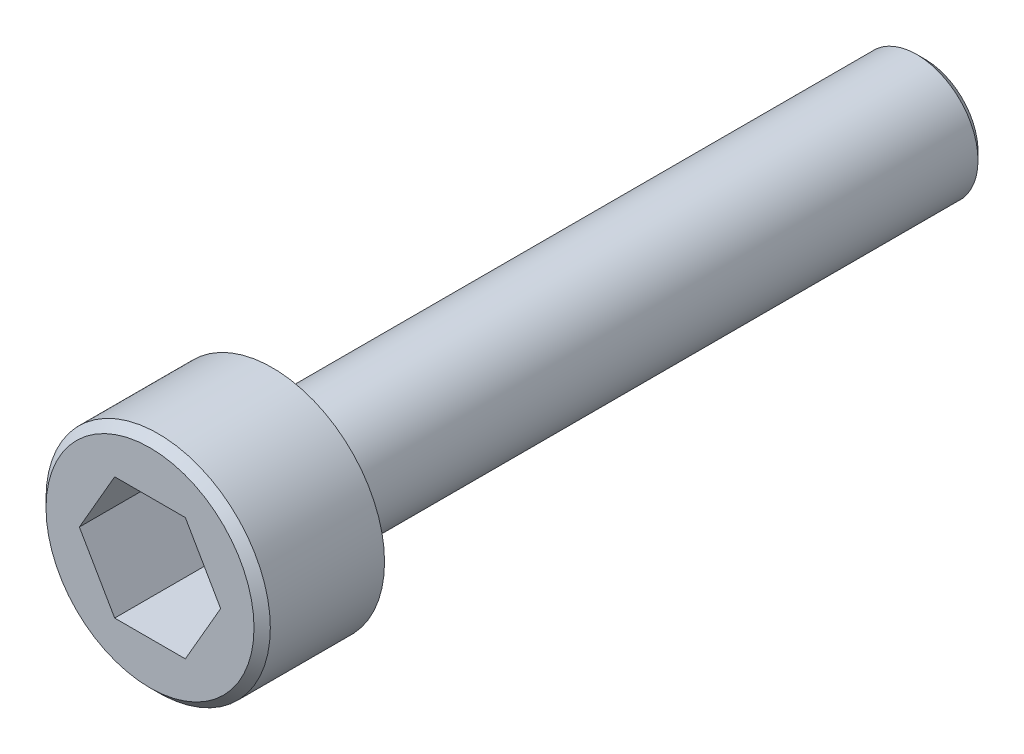
from build123d import *

# Parameters (mm, degrees)
CHAMFER_1_SIZE      = 0.2
CHAMFER_2_SIZE      = 0.2
CUT_EXTRUDE_1_DEPTH = 2.4
EXTRUDE_2_REACH     = 21.394
SKETCH_4_R          = 1.832050808


with BuildPart() as part:
    # Sketch S → Revolve D (revolve)
    with BuildSketch(Plane(origin=(0, 0, 0), x_dir=(-1, 0, 0), z_dir=(0, 1, 0))):
        Polygon((0, 0), (2.75, 0), (2.75, -3), (1.5, -3), (1.5, -19), (0, -19), align=None)
    revolve(axis=Axis((0, 0, 20), (0, 0, -1)))

    # 面取り1
    chamfer_1_edges = [part.edges().sort_by_distance(p)[0] for p in [
        (2.75, 0, 0),
    ]]
    chamfer(chamfer_1_edges, length=CHAMFER_1_SIZE)

    # 面取り2
    chamfer_2_edges = [part.edges().sort_by_distance(p)[0] for p in [
        (1.5, 0, -19),
    ]]
    chamfer(chamfer_2_edges, length=CHAMFER_2_SIZE)

    # ｽｹｯﾁ2 → ｶｯﾄ - 押し出し1 (cut)
    with BuildSketch(Plane(origin=(0, 0, 0), x_dir=(0, 1, 0), z_dir=(0, 0, 1))):
        Polygon((0, 1.732050808), (1.5, 0.866025404), (1.5, -0.866025404), (0, -1.732050808), (-1.5, -0.866025404), (-1.5, 0.866025404), align=None)
    extrude(amount=-CUT_EXTRUDE_1_DEPTH, mode=Mode.SUBTRACT)

    # ｽｹｯﾁ3 → ｶｯﾄ - 回転1 (revolve, cut)
    with BuildSketch(Plane(origin=(0, 0, 0), x_dir=(1, 0, 0), z_dir=(0, 1, 0))):
        Polygon((-1.832050808, 0), (0, 0), (0, 3.4), (-1.832050808, 2.342264973), align=None)
    revolve(axis=Axis((0, 0, -30.07825812), (0, 0, 1)), mode=Mode.SUBTRACT)

    # ｽｹｯﾁ4 → ﾎﾞｽ - 押し出し2 (add, up to next)
    with BuildSketch(Plane.XY, mode=Mode.PRIVATE) as extrude_2_sk1:
        Circle(SKETCH_4_R)
        Polygon((-1.732050808, 0), (-0.866025404, 1.5), (0.866025404, 1.5), (1.732050808, 0), (0.866025404, -1.5), (-0.866025404, -1.5), align=None, mode=Mode.SUBTRACT)
    extrude_2_tool1 = extrude(extrude_2_sk1.sketch, amount=-EXTRUDE_2_REACH, mode=Mode.PRIVATE) - part.part
    add(extrude_2_tool1.solids().sort_by_distance((-1.780233, 0, 0))[0])


solid = part.part
